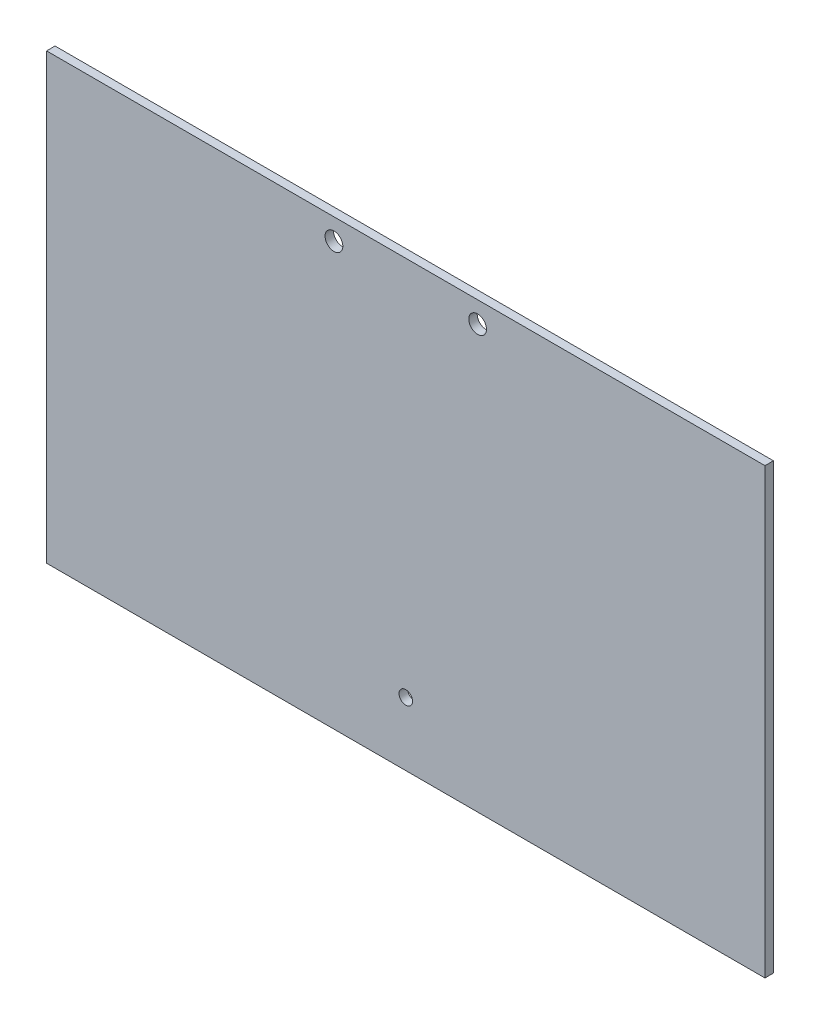
from build123d import *

# Parameters (mm, degrees)
SKETCH_1_W          = 170
SKETCH_1_H          = 105
EXTRUDE_1_DEPTH     = 2
SKETCH_2_R          = 1.6
SKETCH_2_R_2        = 2.1
CUT_EXTRUDE_1_DEPTH = 2


with BuildPart() as part:
    # ｽｹｯﾁ1 → ﾎﾞｽ - 押し出し1 (new body)
    with BuildSketch(Plane.XY):
        Rectangle(SKETCH_1_W, SKETCH_1_H)
    extrude(amount=EXTRUDE_1_DEPTH)

    # ｽｹｯﾁ2 → ｶｯﾄ - 押し出し1 (cut)
    with BuildSketch(Plane.XY.offset(2)):
        with Locations((0, -37.5)):
            Circle(SKETCH_2_R)
        with Locations((17, 47.5)):
            Circle(SKETCH_2_R_2)
        with Locations((-17, 47.5)):
            Circle(SKETCH_2_R_2)
    extrude(amount=-CUT_EXTRUDE_1_DEPTH, mode=Mode.SUBTRACT)


solid = part.part
